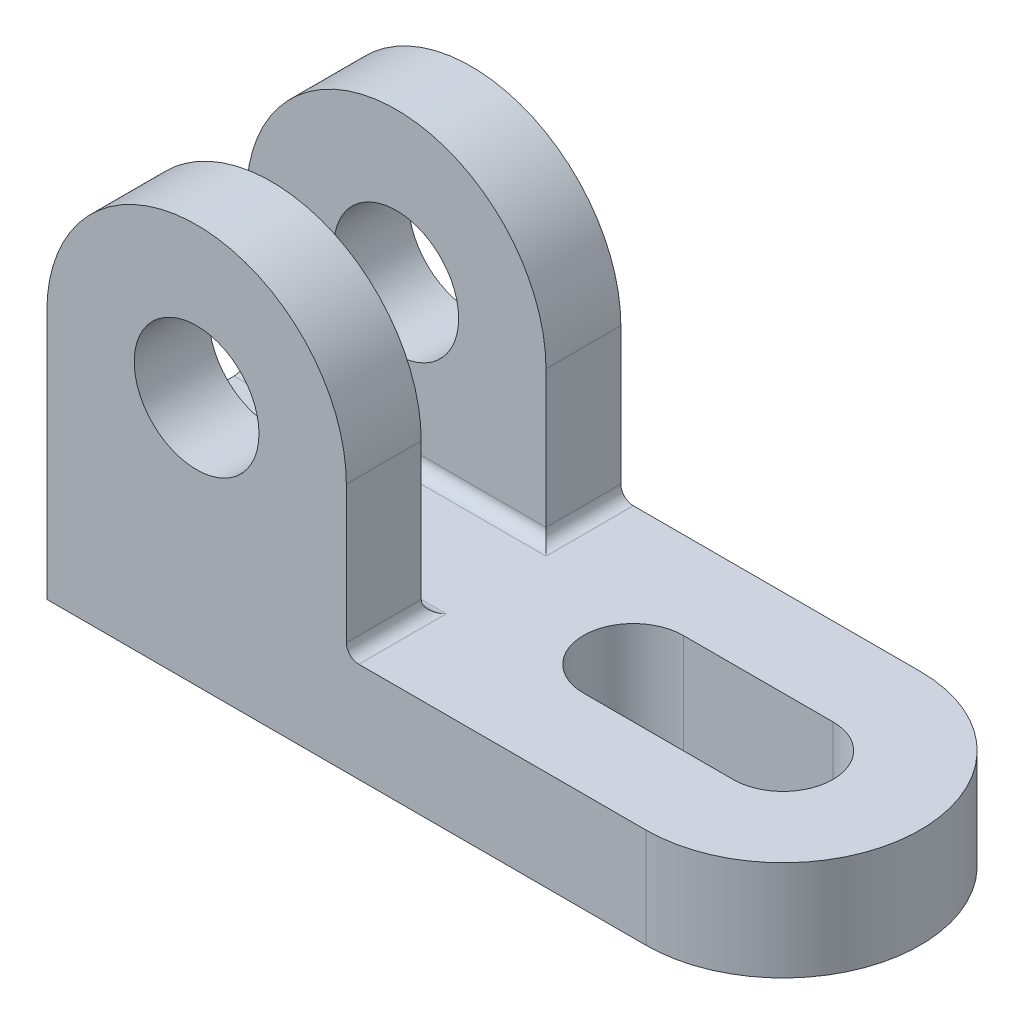
from build123d import *

# Parameters (mm, degrees)
SKETCH1_R           = 22
BOSS_EXTRUDE1_DEPTH = 16
CUT_EXTRUDE1_DEPTH  = 16
BOSS_EXTRUDE2_DEPTH = 12
FILLET1_R           = 2


with BuildPart() as part:
    # Sketch1 → Boss-Extrude1 (new body)
    with BuildSketch(Plane(origin=(0, 0, 0), x_dir=(1, 0, 0), z_dir=(0, 1, 0))):
        with BuildLine():
            Line((37.000000064, 22), (-59, 22))
            Line((-59, 22), (-59, -22))
            Line((-59, -22), (37, -22))
            ThreePointArc((37, -22), (15, 3.2e-08), (37.000000064, 22))
        make_face()
        with Locations((37, 0)):
            Circle(SKETCH1_R)
    extrude(amount=BOSS_EXTRUDE1_DEPTH)

    # Sketch4 → Cut-Extrude1 (cut)
    with BuildSketch(Plane(origin=(0, 16, 0), x_dir=(1, 0, 0), z_dir=(0, 1, 0))):
        with BuildLine():
            Line((37, -8), (13, -8))
            ThreePointArc((13, -8), (5, 0), (13, 8))
            Line((13, 8), (37, 8))
            ThreePointArc((37, 8), (45, 0), (37, -8))
        make_face()
    extrude(amount=-CUT_EXTRUDE1_DEPTH, mode=Mode.SUBTRACT)

    # Sketch5 → Boss-Extrude2 (add)
    with BuildSketch(Plane.XY.offset(22)):
        with BuildLine():
            ThreePointArc((-59, 40), (-51.970562748, 23.029437252), (-35, 16))
            ThreePointArc((-35, 16), (-18.029437252, 23.029437252), (-11, 40))
            Line((-11, 40), (-25, 40))
            ThreePointArc((-25, 40), (-35, 30), (-45, 40))
            Line((-45, 40), (-59, 40))
        make_face()
        with BuildLine():
            ThreePointArc((-11, 40), (-35, 64), (-59, 40))
            Line((-59, 40), (-45, 40))
            ThreePointArc((-45, 40), (-35, 50), (-25, 40))
            Line((-25, 40), (-11, 40))
        make_face()
        with BuildLine():
            Line((-59, 40), (-59, 16))
            Line((-59, 16), (-35, 16))
            ThreePointArc((-35, 16), (-51.970562748, 23.029437252), (-59, 40))
        make_face()
        with BuildLine():
            ThreePointArc((-11, 40), (-18.029437252, 23.029437252), (-35, 16))
            Line((-35, 16), (-11, 16))
            Line((-11, 16), (-11, 40))
        make_face()
    boss_extrude2 = extrude(amount=-BOSS_EXTRUDE2_DEPTH)

    # Mirror1: Boss-Extrude2 across plane
    add(boss_extrude2.mirror(Plane.XY))

    # Fillet1
    fillet1_edges = [part.edges().sort_by_distance(p)[0] for p in [
        (-11, 16, 16),
        (-35, 16, 10),
        (-35, 16, -10),
        (-11, 16, -16),
    ]]
    fillet(fillet1_edges, radius=FILLET1_R)


solid = part.part
